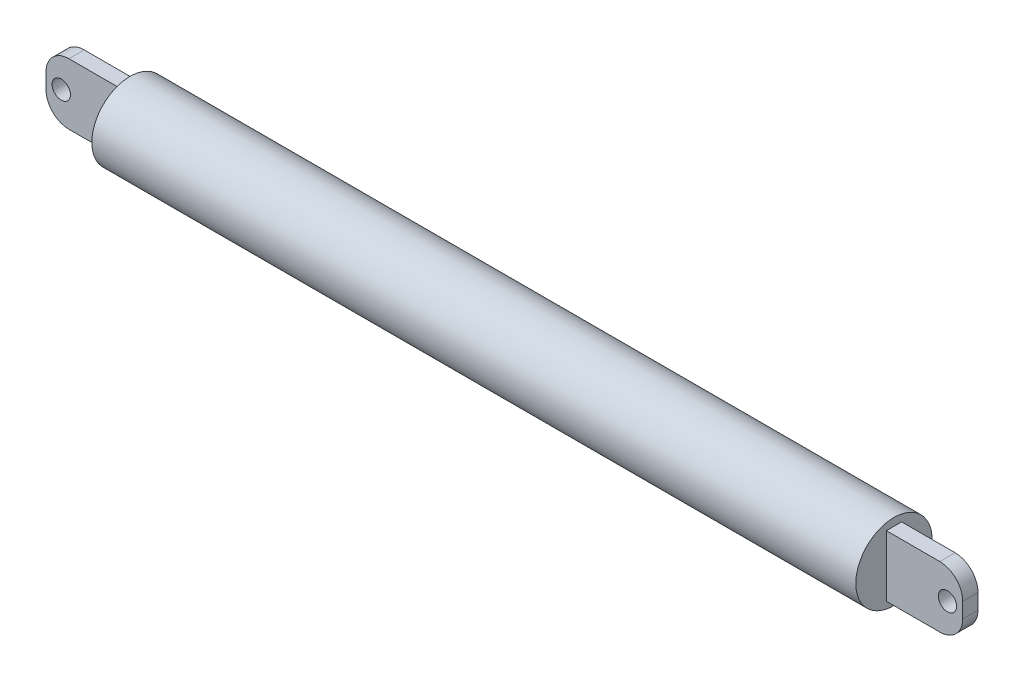
from build123d import *

# Parameters (mm, degrees)
ESBO_O1_W                = 500
ESBO_O1_H                = 25
ESBO_O2_R                = 6
RESSALTO_EXTRUS_O1_DEPTH = 5


with BuildPart() as part:
    # Esboço1 → Revolução1 (revolve)
    with BuildSketch(Plane.XY):
        with Locations((0, 12.5)):
            Rectangle(ESBO_O1_W, ESBO_O1_H)
    revolve(axis=Axis((0, 0, 0), (1, 0, 0)))

    # Esboço2 → Ressalto-extrusão1 (add, symmetric)
    with BuildSketch(Plane.XY):
        with BuildLine():
            Line((250, -20), (250, 20))
            Line((250, 20), (285, 20))
            ThreePointArc((285, 20), (295.606601718, 15.606601718), (300, 5))
            Line((300, 5), (300, -5))
            ThreePointArc((300, -5), (295.606601718, -15.606601718), (285, -20))
            Line((285, -20), (250, -20))
        make_face()
        with Locations((290, 0)):
            Circle(ESBO_O2_R, mode=Mode.SUBTRACT)
    ressalto_extrus_o1 = extrude(amount=RESSALTO_EXTRUS_O1_DEPTH, both=True)

    # Espelhar1: Ressalto-extrusão1 across plane
    add(ressalto_extrus_o1.mirror(Plane(origin=(0, 0, 0), x_dir=(0, 0, 1), z_dir=(1, 0, 0))))


solid = part.part
